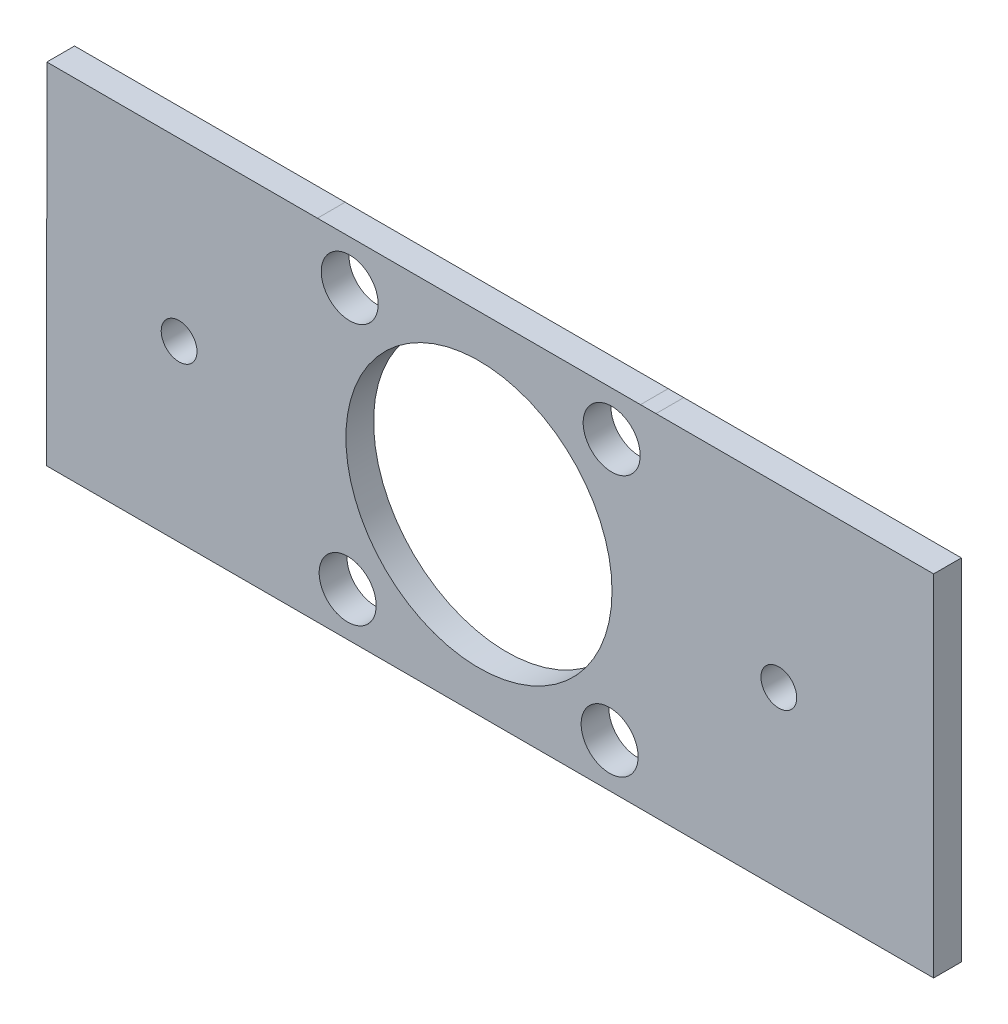
from build123d import *

# Parameters (mm, degrees)
MODEL_R             = 3.2639
MODEL_R_2           = 15.24
BOSS_EXTRUDE1_DEPTH = 3.175
SKETCH1_R           = 2.049665702
CUT_EXTRUDE1_DEPTH  = 4.175


with BuildPart() as part:
    # Model → Boss-Extrude1 (new body)
    with BuildSketch(Plane.XY):
        Polygon((52.780663663, 19.962036807), (84.57472724, 19.962036807), (84.57472724, -20.117524571), (52.800441441, -20.117524571), (51.022441441, -20.110851742), (13.987013039, -20.110851742), (-17.005125185, -20.115733226), (-16.985347623, 19.94996289), (14.006790818, 19.955743846), (51.002663663, 19.962109065), align=None)
        with Locations((17.703224546, 14.890349751)):
            Circle(MODEL_R, mode=Mode.SUBTRACT)
        with Locations((47.70316443, 14.892992778)):
            Circle(MODEL_R, mode=Mode.SUBTRACT)
        with Locations((17.469307033, -15.107191493)):
            Circle(MODEL_R, mode=Mode.SUBTRACT)
        with Locations((47.46924701, -15.106035251)):
            Circle(MODEL_R, mode=Mode.SUBTRACT)
        with Locations((32.50472724, -0.168751446)):
            Circle(MODEL_R_2, mode=Mode.SUBTRACT)
    extrude(amount=-BOSS_EXTRUDE1_DEPTH)

    # Sketch1 → Cut-Extrude1 (cut, through all)
    with BuildSketch(Plane(origin=(0, 0, -3.175), x_dir=(-1, 0, 0), z_dir=(0, 0, -1))):
        with Locations((1.835627279, -0.168751446)):
            Circle(SKETCH1_R)
        with Locations((-66.84508176, -0.168751446)):
            Circle(SKETCH1_R)
    extrude(amount=-CUT_EXTRUDE1_DEPTH, mode=Mode.SUBTRACT)


solid = part.part
